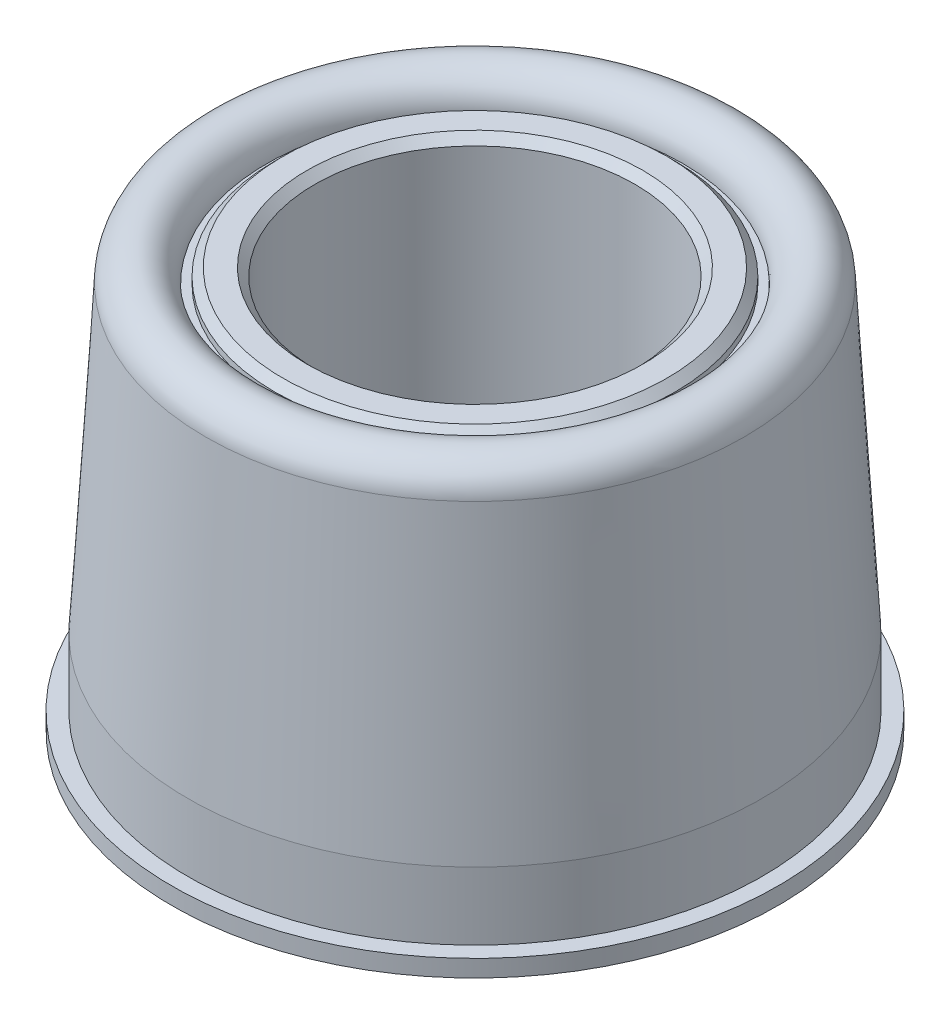
from build123d import *

# Parameters (mm, degrees)
SKETCH3_W     = 1.885
SKETCH3_H     = 18.0848
CHAMFER1_SIZE = 0.37575
SKETCH4_W     = 0.38
SKETCH4_H     = 17.367868501


with BuildPart() as part:
    # Sketch2 → Outer (revolve)
    with BuildSketch(Plane.XY):
        with BuildLine():
            Line((-14.25, -9.8), (-14.25, -9))
            Line((-14.25, -9), (-13.49, -9))
            Line((-13.49, -9), (-13.49, -5.825))
            Line((-13.49, -5.825), (-12.6417422, 8.452803027))
            ThreePointArc((-12.6417422, 8.452803027), (-11.169645536, 9.799369662), (-9.78, 8.367868501))
            Line((-9.78, 8.367868501), (-9.78, -9.8))
            Line((-9.78, -9.8), (-14.25, -9.8))
        make_face()
    revolve(axis=Axis((0, -9.0424, 0), (0, 1, 0)))



with BuildPart() as body_2:
    # Sketch3 → Inner (revolve)
    with BuildSketch(Plane.XY):
        with Locations((-8.4575, 0)):
            Rectangle(SKETCH3_W, SKETCH3_H)
    revolve(axis=Axis((0, -9.0424, 0), (0, 1, 0)))

    # Chamfer1
    chamfer1_edges = [body_2.edges().sort_by_distance(p)[0] for p in [
        (7.515, 9.0424, 0),
        (7.515, -9.0424, 0),
        (9.4, -9.0424, 0),
        (9.4, 9.0424, 0),
    ]]
    chamfer(chamfer1_edges, length=CHAMFER1_SIZE)


with BuildPart() as part_1:
    add(part.part)

    add(body_2.part)  # Combine merges body 2
    # Sketch4 → Combine (revolve)
    with BuildSketch(Plane.XY):
        with Locations((-9.59, -0.316065749)):
            Rectangle(SKETCH4_W, SKETCH4_H)
    revolve(axis=Axis((0, -9.0424, 0), (0, 1, 0)))


solid = part_1.part
